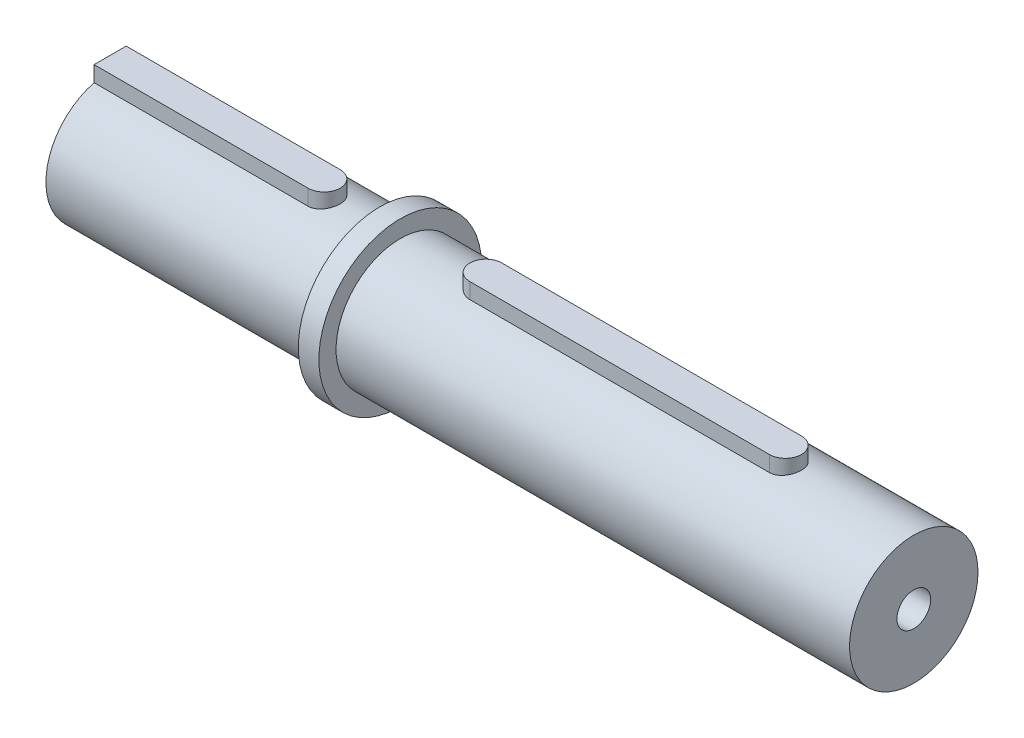
from build123d import *

# Parameters (mm, degrees)
SKETCH1_R             = 12.0777
BOSS_EXTRUDE1_DEPTH   = 3.048
SKETCH2_R             = 9.525
BOSS_EXTRUDE2_DEPTH   = 40
SKETCH3_R             = 9.525
BOSS_EXTRUDE3_DEPTH   = 76.2
M6_TAPPED_HOLE1_D     = 5
M6_TAPPED_HOLE1_DEPTH = 14.986
M6_TAPPED_HOLE1_TIP   = 1.502151548
BOSS_EXTRUDE4_DEPTH   = 4.7625


with BuildPart() as part:
    # Sketch1 → Boss-Extrude1 (new body)
    with BuildSketch(Plane(origin=(0, 0, 0), x_dir=(0, 0, -1), z_dir=(1, 0, 0))):
        Circle(SKETCH1_R)
    extrude(amount=-BOSS_EXTRUDE1_DEPTH)

    # Sketch2 → Boss-Extrude2 (add)
    with BuildSketch(Plane.ZY.offset(3.048)):
        Circle(SKETCH2_R)
    extrude(amount=BOSS_EXTRUDE2_DEPTH)

    # Sketch3 → Boss-Extrude3 (add)
    with BuildSketch(Plane(origin=(0, 0, 0), x_dir=(0, 0, -1), z_dir=(1, 0, 0))):
        Circle(SKETCH3_R)
    extrude(amount=BOSS_EXTRUDE3_DEPTH)

    # M6 Tapped Hole1
    with Locations(Plane(origin=(76.2, 0, 0), x_dir=(0, 0, -1), z_dir=(1, 0, 0))):
        with Locations((0, 0)):
            Hole(M6_TAPPED_HOLE1_D / 2, depth=M6_TAPPED_HOLE1_DEPTH)
            with Locations((0, 0, -(M6_TAPPED_HOLE1_DEPTH + M6_TAPPED_HOLE1_TIP / 2))):  # 118° drill point
                Cone(0, M6_TAPPED_HOLE1_D / 2, M6_TAPPED_HOLE1_TIP, mode=Mode.SUBTRACT)

    # Sketch33 → Boss-Extrude4 (add)
    with BuildSketch(Plane(origin=(0, 6.7818, 0), x_dir=(1, 0, 0), z_dir=(0, 1, 0))):
        with BuildLine():
            Line((12.7, 2.38125), (57.15, 2.38125))
            ThreePointArc((57.15, 2.38125), (59.53125, 0), (57.15, -2.38125))
            Line((57.15, -2.38125), (12.7, -2.38125))
            ThreePointArc((12.7, -2.38125), (10.31875, 0), (12.7, 2.38125))
        make_face()
        with BuildLine():
            Line((-43.048, 2.38125), (-11.298, 2.38125))
            ThreePointArc((-11.298, 2.38125), (-8.91675, 0), (-11.298, -2.38125))
            Line((-11.298, -2.38125), (-43.048, -2.38125))
            Line((-43.048, -2.38125), (-43.048, 2.38125))
        make_face()
    extrude(amount=BOSS_EXTRUDE4_DEPTH)


solid = part.part
